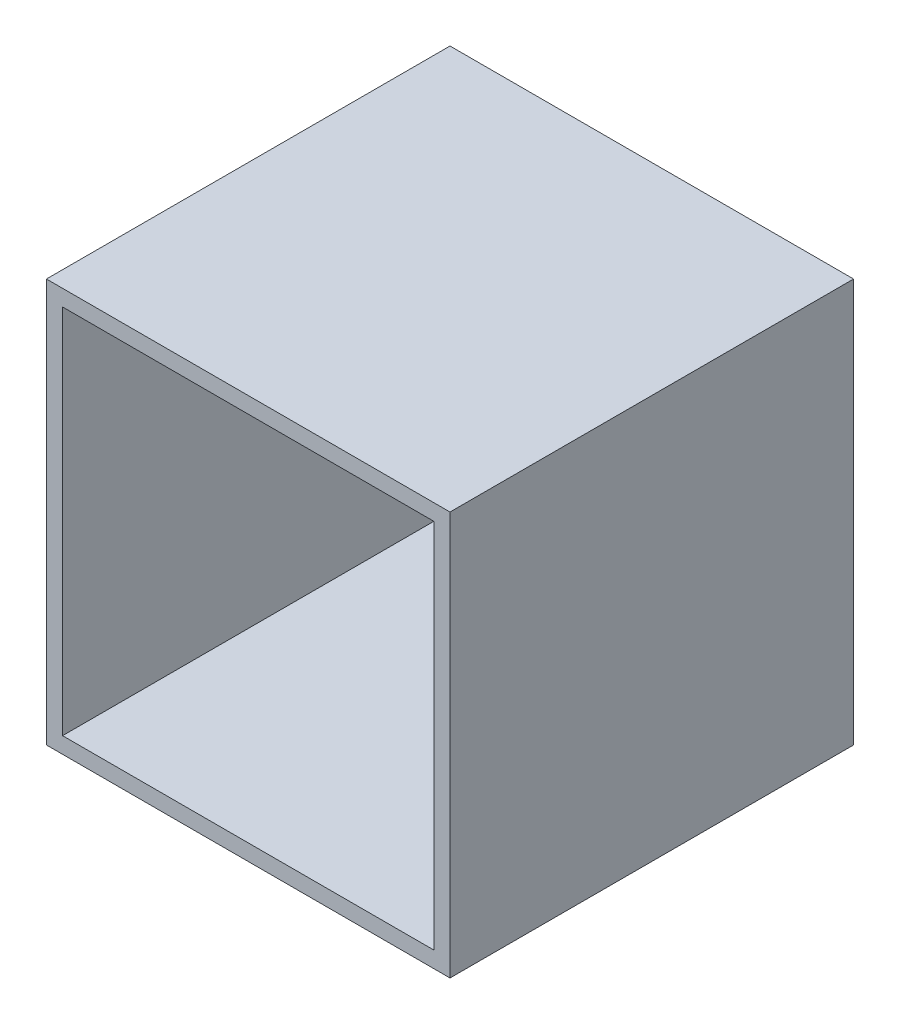
from build123d import *

# Parameters (mm, degrees)
SKETCH1_W           = 10
SKETCH1_H           = 10
BOSS_EXTRUDE1_DEPTH = 0.4
SKETCH2_W           = 10
SKETCH2_H           = 10
SKETCH2_W_2         = 9.2
SKETCH2_H_2         = 9.2
BOSS_EXTRUDE2_DEPTH = 9.6


with BuildPart() as part:
    # Sketch1 → Boss-Extrude1 (new body)
    with BuildSketch(Plane.XY):
        Rectangle(SKETCH1_W, SKETCH1_H)
    extrude(amount=BOSS_EXTRUDE1_DEPTH)

    # Sketch2 → Boss-Extrude2 (add)
    with BuildSketch(Plane.XY.offset(0.4)):
        Rectangle(SKETCH2_W, SKETCH2_H)
        Rectangle(SKETCH2_W_2, SKETCH2_H_2, mode=Mode.SUBTRACT)
    extrude(amount=BOSS_EXTRUDE2_DEPTH)


solid = part.part
